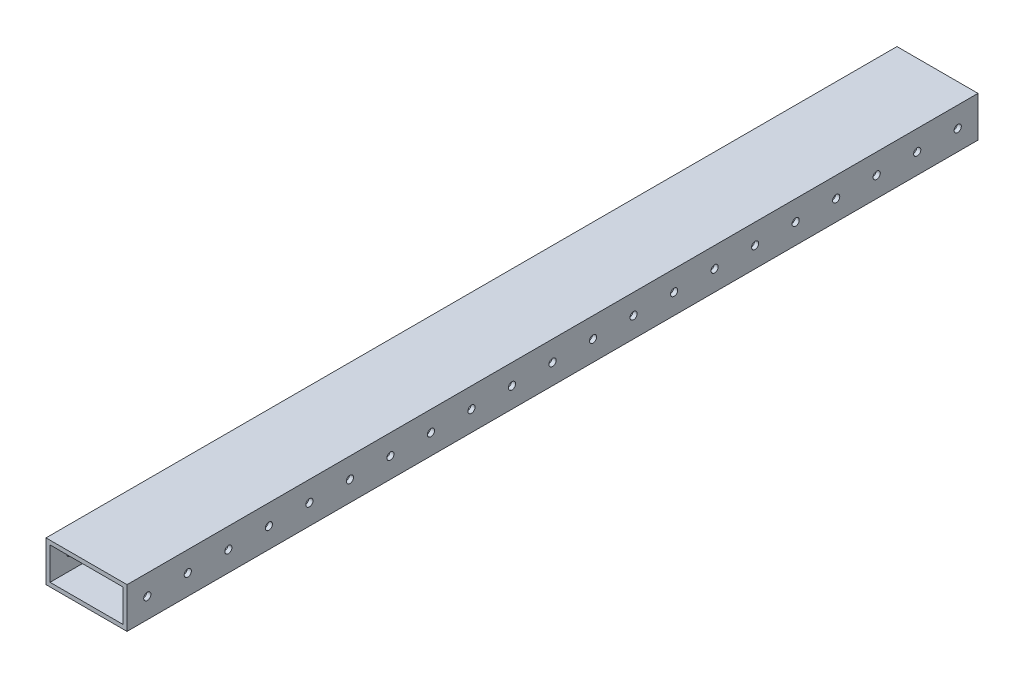
from build123d import *

# Parameters (mm, degrees)
SKETCH1_W             = 50.8
SKETCH1_H             = 25.4
SKETCH1_W_2           = 45.72
SKETCH1_H_2           = 20.32
BOSS_EXTRUDE1_DEPTH   = 533.4
F_8_CLEARANCE_HOLE1_D = 4.4958


with BuildPart() as part:
    # Sketch1 → Boss-Extrude1 (new body)
    with BuildSketch(Plane.XY):
        Rectangle(SKETCH1_W, SKETCH1_H)
        Rectangle(SKETCH1_W_2, SKETCH1_H_2, mode=Mode.SUBTRACT)
    extrude(amount=-BOSS_EXTRUDE1_DEPTH)

    # #8 Clearance Hole1 (through all)
    with Locations(Plane(origin=(25.4, 0, 0), x_dir=(0, 0, -1), z_dir=(1, 0, 0))):
        with Locations((12.7, 0), (38.1, 0), (63.5, 0), (88.9, 0), (114.3, 0), (139.7, 0), (165.1, 0), (190.5, 0), (215.9, 0), (241.3, 0), (266.7, 0), (292.1, 0), (317.5, 0), (342.9, 0), (368.3, 0), (393.7, 0), (419.1, 0), (444.5, 0), (469.9, 0), (495.3, 0), (520.7, 0)):
            Hole(F_8_CLEARANCE_HOLE1_D / 2)


solid = part.part
